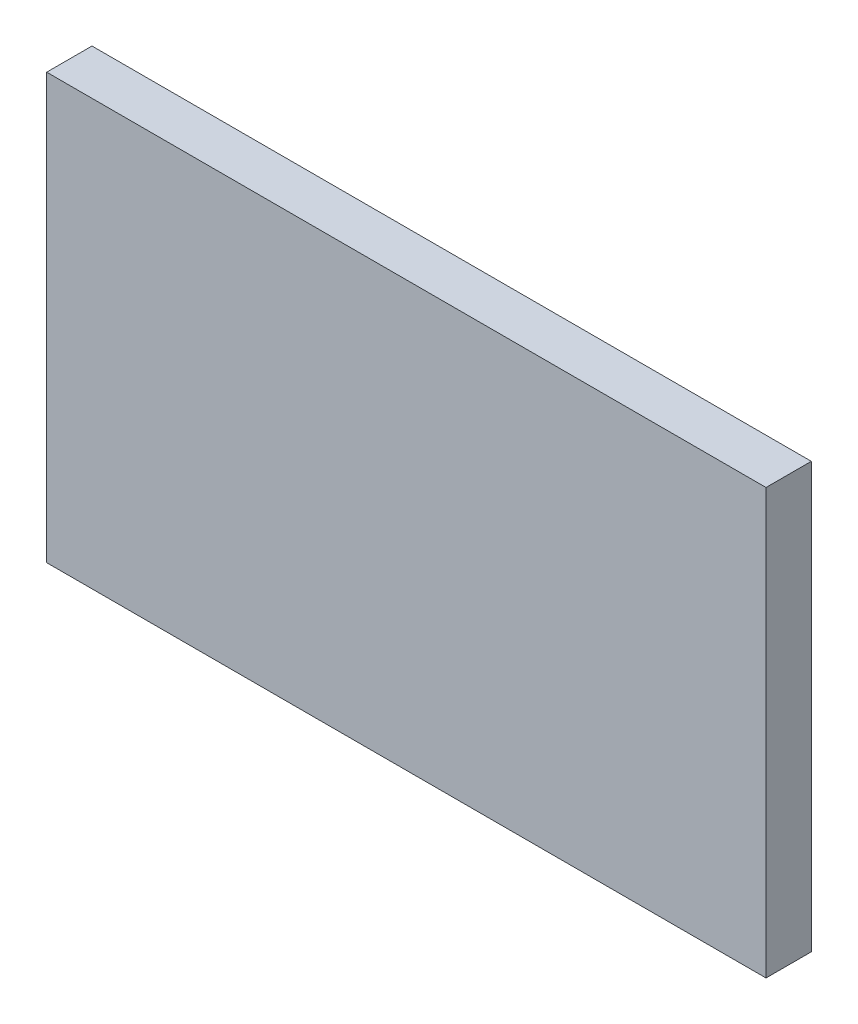
from build123d import *

# Parameters (mm, degrees)
CROQUIS1_W              = 101.6
CROQUIS1_H              = 60
SALIENTE_EXTRUIR1_DEPTH = 6.4


with BuildPart() as part:
    # Croquis1 → Saliente-Extruir1 (new body)
    with BuildSketch(Plane.XY):
        with Locations((50.8, 30)):
            Rectangle(CROQUIS1_W, CROQUIS1_H)
    extrude(amount=SALIENTE_EXTRUIR1_DEPTH)


solid = part.part
